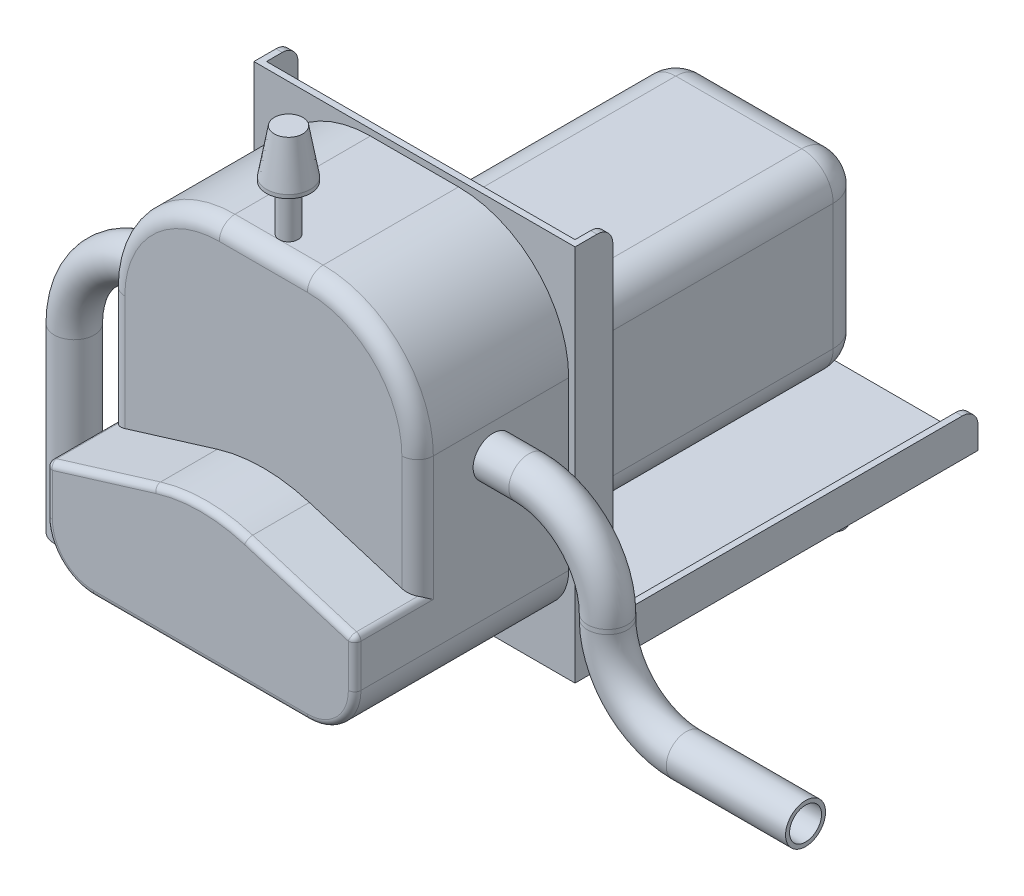
from build123d import *

# Parameters (mm, degrees)
SKETCH1_W           = 102
SKETCH1_H           = 120
BOSS_EXTRUDE1_DEPTH = 2
SKETCH2_W           = 102
SKETCH2_H           = 128
BOSS_EXTRUDE2_DEPTH = 2
BOSS_EXTRUDE3_DEPTH = 2
FILLET1_R           = 5
SKETCH5_R           = 3.5
SKETCH5_R_2         = 2.5
BOSS_EXTRUDE4_DEPTH = 6
SKETCH4_W           = 98
SKETCH4_H           = 103
BOSS_EXTRUDE5_DEPTH = 68
FILLET2_R           = 35
FILLET3_R           = 15
CUT_EXTRUDE1_DEPTH  = 20
FILLET4_R           = 5
FILLET5_R           = 2
SKETCH8_W           = 60
SKETCH8_H           = 60
BOSS_EXTRUDE6_DEPTH = 111
FILLET6_R           = 10
SKETCH10_R          = 3
BOSS_EXTRUDE7_DEPTH = 29.85
SKETCH11_R          = 7
BOSS_EXTRUDE8_DEPTH = 15.15
CHAMFER1_SIZE       = 14
CHAMFER1_SIZE2      = 2.46857773
CUT_EXTRUDE2_DEPTH  = 38
SKETCH12_R          = 6.35
SKETCH12_R_2        = 5.08


with BuildPart() as part:
    # Sketch1 → Boss-Extrude1 (new body)
    with BuildSketch(Plane.XY):
        Rectangle(SKETCH1_W, SKETCH1_H)
    extrude(amount=BOSS_EXTRUDE1_DEPTH)

    # Sketch2 → Boss-Extrude2 (add)
    with BuildSketch(Plane.XZ.offset(60)):
        with Locations((0, -62)):
            Rectangle(SKETCH2_W, SKETCH2_H)
    extrude(amount=-BOSS_EXTRUDE2_DEPTH)

    # Sketch3 → Boss-Extrude3 (add)
    with BuildSketch(Plane(origin=(51, 0, 0), x_dir=(0, 0, -1), z_dir=(1, 0, 0))):
        Polygon((-2, 60), (10, 60), (10, -48), (126, -48), (126, -60), (-2, -60), (-2, -48), align=None)
    boss_extrude3 = extrude(amount=-BOSS_EXTRUDE3_DEPTH)

    # Mirror1: Boss-Extrude3 across plane
    add(boss_extrude3.mirror(Plane(origin=(0, 0, 0), x_dir=(0, 0, 1), z_dir=(1, 0, 0))))

    # Fillet1
    fillet1_edges = [part.edges().sort_by_distance(p)[0] for p in [
        (50, -48, -126),
        (50, 60, -10),
        (-50, -48, -126),
        (-50, 60, -10),
    ]]
    fillet(fillet1_edges, radius=FILLET1_R)

    # Sketch5 → Boss-Extrude4 (add)
    with BuildSketch(Plane.XZ.offset(60)):
        with Locations((-42, -13)):
            Circle(SKETCH5_R)
        with Locations((-42, -13)):
            Circle(SKETCH5_R_2, mode=Mode.SUBTRACT)
        with Locations((42, -13)):
            Circle(SKETCH5_R)
        with Locations((42, -13)):
            Circle(SKETCH5_R_2, mode=Mode.SUBTRACT)
        with Locations((-42, -89)):
            Circle(SKETCH5_R)
        with Locations((-42, -89)):
            Circle(SKETCH5_R_2, mode=Mode.SUBTRACT)
        with Locations((42, -89)):
            Circle(SKETCH5_R)
        with Locations((42, -89)):
            Circle(SKETCH5_R_2, mode=Mode.SUBTRACT)
    extrude(amount=BOSS_EXTRUDE4_DEPTH)

    # Sketch4 → Boss-Extrude5 (add)
    with BuildSketch(Plane.XY.offset(2)):
        with Locations((0, 6.5)):
            Rectangle(SKETCH4_W, SKETCH4_H)
    extrude(amount=BOSS_EXTRUDE5_DEPTH)

    # Fillet2
    fillet2_edges = [part.edges().sort_by_distance(p)[0] for p in [
        (-49, 58, 36),
        (49, 58, 36),
    ]]
    fillet(fillet2_edges, radius=FILLET2_R)

    # Fillet3
    fillet3_edges = [part.edges().sort_by_distance(p)[0] for p in [
        (-49, -45, 36),
        (49, -45, 36),
    ]]
    fillet(fillet3_edges, radius=FILLET3_R)

    # Sketch6 → Cut-Extrude1 (cut)
    with BuildSketch(Plane.XY.offset(70)):
        with BuildLine():
            Line((-49, -15), (-14.635713605, -4.480320491))
            ThreePointArc((-14.635713605, -4.480320491), (0, -2.290318267), (14.635713605, -4.480320491))
            Line((14.635713605, -4.480320491), (49, -15))
            Line((49, -15), (49, 23))
            ThreePointArc((49, 23), (38.748737342, 47.748737342), (14, 58))
            Line((14, 58), (-14, 58))
            ThreePointArc((-14, 58), (-38.748737342, 47.748737342), (-49, 23))
            Line((-49, 23), (-49, -15))
        make_face()
    extrude(amount=-CUT_EXTRUDE1_DEPTH, mode=Mode.SUBTRACT)

    # Fillet4
    fillet4_edges = [part.edges().sort_by_distance(p)[0] for p in [
        (-49, 4, 50),
        (-38.748737342, 47.748737342, 50),
        (0, 58, 50),
        (38.748737342, 47.748737342, 50),
        (49, 4, 50),
    ]]
    fillet(fillet4_edges, radius=FILLET4_R)

    # Fillet5
    fillet5_edges = [part.edges().sort_by_distance(p)[0] for p in [
        (-31.817856802, -9.740160246, 70),
        (31.817856802, -9.740160246, 70),
        (-49, -15, 60),
        (49, -15, 60),
        (0, -2.290318267, 70),
        (-49, -22.5, 70),
        (-44.606601718, -40.606601718, 70),
        (0, -45, 70),
        (44.606601718, -40.606601718, 70),
        (49, -22.5, 70),
    ]]
    fillet(fillet5_edges, radius=FILLET5_R)

    # Sketch8 → Boss-Extrude6 (add)
    with BuildSketch(Plane(origin=(0, 0, 0), x_dir=(-1, 0, 0), z_dir=(0, 0, -1))):
        with Locations((0, -10)):
            Rectangle(SKETCH8_W, SKETCH8_H)
    extrude(amount=BOSS_EXTRUDE6_DEPTH)

    # Fillet6
    fillet6_edges = [part.edges().sort_by_distance(p)[0] for p in [
        (-30, -40, -55.5),
        (-30, 20, -55.5),
        (30, 20, -55.5),
        (30, -40, -55.5),
        (0, -40, -111),
        (-30, -10, -111),
        (0, 20, -111),
        (30, -10, -111),
    ]]
    fillet(fillet6_edges, radius=FILLET6_R)

    # Sketch10 → Boss-Extrude7 (add)
    with BuildSketch(Plane(origin=(0, 58, 0), x_dir=(1, 0, 0), z_dir=(0, 1, 0))):
        with Locations((0, -42)):
            Circle(SKETCH10_R)
    extrude(amount=BOSS_EXTRUDE7_DEPTH)

    # Sketch11 → Boss-Extrude8 (add)
    with BuildSketch(Plane(origin=(0, 87.85, 0), x_dir=(1, 0, 0), z_dir=(0, 1, 0))):
        with Locations((0, -42)):
            Circle(SKETCH11_R)
    extrude(amount=-BOSS_EXTRUDE8_DEPTH)

    # Chamfer1
    chamfer1_edges = [part.edges().sort_by_distance(p)[0] for p in [
        (-7, 87.85, 42),
    ]]
    chamfer1_side = [part.faces().sort_by_distance(p)[0] for p in [
        (-7, 80.275, 42),
    ]]
    chamfer(chamfer1_edges, length=CHAMFER1_SIZE, length2=CHAMFER1_SIZE2, reference=chamfer1_side[0])

    # Sketch15 → Cut-Extrude2 (cut)
    with BuildSketch(Plane.XY.offset(2)):
        with BuildLine():
            Line((44, -13.469387755), (44, 23))
            ThreePointArc((44, 23), (35.213203436, 44.213203436), (14, 53))
            Line((14, 53), (-14, 53))
            ThreePointArc((-14, 53), (-35.213203436, 44.213203436), (-44, 23))
            Line((-44, 23), (-44, -13.469387755))
            Line((-44, -13.469387755), (-44, -16.479367833))
            Line((-44, -16.479367833), (-44, -30))
            ThreePointArc((-44, -30), (-41.071067812, -37.071067812), (-34, -40))
            Line((-34, -40), (34, -40))
            ThreePointArc((34, -40), (41.071067812, -37.071067812), (44, -30))
            Line((44, -30), (44, -16.479367833))
            Line((44, -16.479367833), (44, -13.469387755))
        make_face()
    extrude(amount=CUT_EXTRUDE2_DEPTH, mode=Mode.SUBTRACT)

    # Sweep1: sweep along a path in Sketch13
    with BuildLine(Plane.XY.offset(50)) as sweep1_path:
        Line((148.244758881, -37.996072563), (110.346237014, -37.996072563))
        ThreePointArc((110.346237014, -37.996072563), (92.668567485, -30.673742092), (85.346237014, -12.996072563))
        Line((85.346237014, -12.996072563), (85.346237014, -11.571323289))
        ThreePointArc((85.346237014, -11.571323289), (78.023906544, 6.10634624), (60.346237014, 13.428676711))
        Line((60.346237014, 13.428676711), (-54.047136689, 13.428676711))
        ThreePointArc((-54.047136689, 13.428676711), (-75.260340125, 4.641880146), (-84.047136689, -16.571323289))
        Line((-84.047136689, -16.571323289), (-84.047136689, -73.938085058))
    # Sketch12 → Sweep1 (sweep)
    with BuildSketch(Plane.ZY.offset(49)):
        with Locations((26.021639794, 13.428676711)):
            Circle(SKETCH12_R)
        with Locations((26.021639794, 13.428676711)):
            Circle(SKETCH12_R_2, mode=Mode.SUBTRACT)
    sweep(path=sweep1_path.line)


solid = part.part
